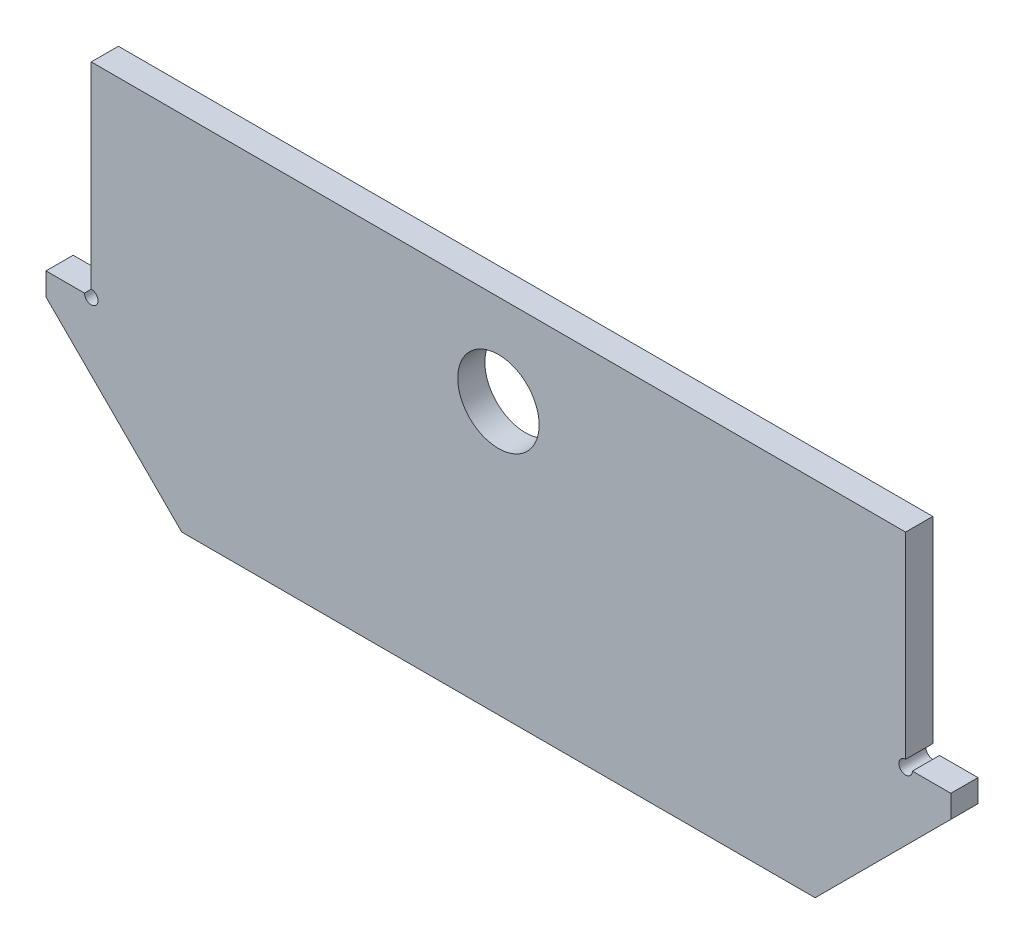
from build123d import *

# Parameters (mm, degrees)
BOSS_EXTRUDE1_DEPTH      = 3
BOSS_EXTRUDE1_DEPTH_BACK = 3
SKETCH2_R                = 9
CUT_EXTRUDE1_DEPTH       = 1
CUT_EXTRUDE1_DEPTH_BACK  = 7
SKETCH3_R                = 1.5
CUT_EXTRUDE2_DEPTH       = 1
CUT_EXTRUDE2_DEPTH_BACK  = 7


with BuildPart() as part:
    # Sketch1 → Boss-Extrude1 (new body, two sides)
    with BuildSketch(Plane.XY) as boss_extrude1_sk:
        Polygon((-90, -1414), (-90, -1369), (90, -1369), (90, -1414), (100, -1414), (100, -1419), (70, -1449), (-70, -1449), (-100, -1419), (-100, -1414), align=None)
    extrude(amount=BOSS_EXTRUDE1_DEPTH)
    extrude(boss_extrude1_sk.sketch, amount=-BOSS_EXTRUDE1_DEPTH_BACK)

    # Sketch2 → Cut-Extrude1 (cut, two sides)
    with BuildSketch(Plane.XY.offset(3)) as cut_extrude1_sk:
        with Locations((0, -1389)):
            Circle(SKETCH2_R)
    extrude(amount=CUT_EXTRUDE1_DEPTH, mode=Mode.SUBTRACT)
    extrude(cut_extrude1_sk.sketch, amount=-CUT_EXTRUDE1_DEPTH_BACK, mode=Mode.SUBTRACT)

    # Sketch3 → Cut-Extrude2 (cut, two sides)
    with BuildSketch(Plane.XY.offset(3)) as cut_extrude2_sk:
        with Locations((-90, -1414)):
            Circle(SKETCH3_R)
        with Locations((90, -1414)):
            Circle(SKETCH3_R)
    extrude(amount=CUT_EXTRUDE2_DEPTH, mode=Mode.SUBTRACT)
    extrude(cut_extrude2_sk.sketch, amount=-CUT_EXTRUDE2_DEPTH_BACK, mode=Mode.SUBTRACT)


solid = part.part
